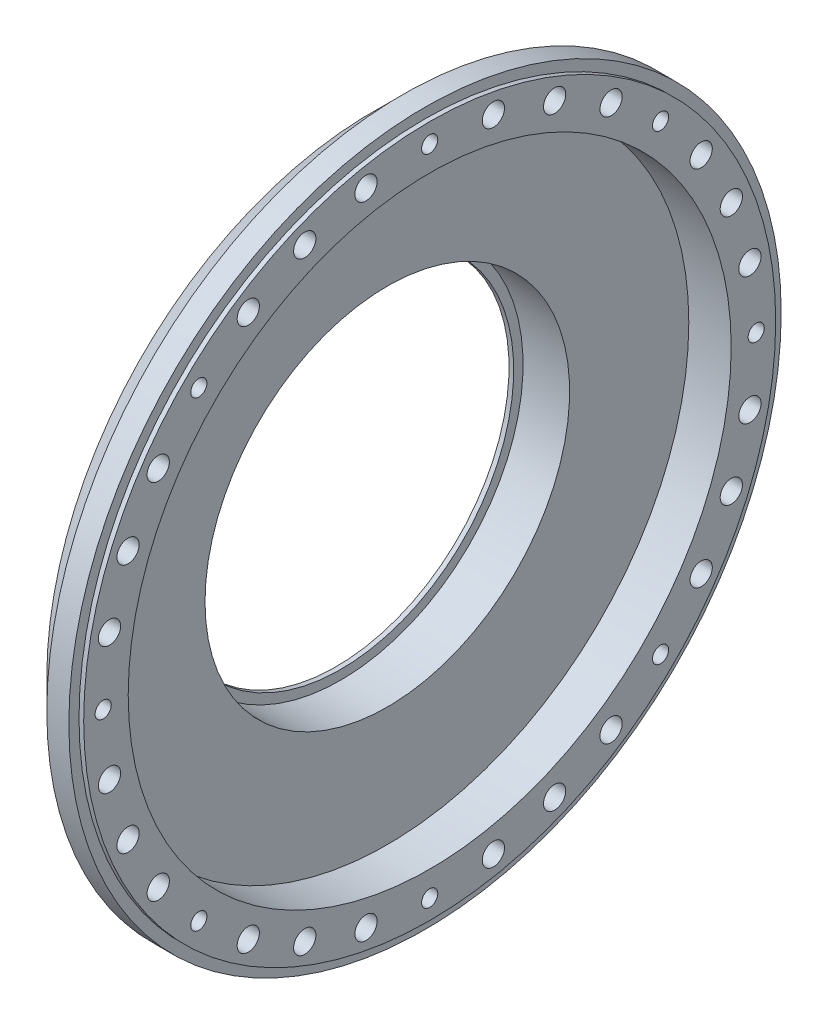
from build123d import *

# Parameters (mm, degrees)
SKETCH5_R          = 2.38125
CUT_EXTRUDE1_DEPTH = 4.445
SKETCH6_R          = 1.7272
CUT_EXTRUDE2_DEPTH = 9.525


with BuildPart() as part:
    # Sketch4 → Revolve1 (revolve)
    with BuildSketch(Plane.XY):
        Polygon((7.249924984, 74.025000032), (6.249924952, 74.025000032), (6.249924952, 76.2), (1.53480008, 76.2), (-4.81519992, 69.85), (-4.81519992, 55.24999999), (-12.775199748, 47.290000162), (-12.775199748, 36.999999914), (-11.775199716, 36.999999914), (-11.775199716, 38.999999978), (-1.815199824, 38.999999978), (-1.815199824, 64.500000032), (7.249924984, 64.500000032), align=None)
    revolve(axis=Axis((0, 0, 0), (1, 0, 0)))

    # Sketch5 → Cut-Extrude1 (cut)
    with BuildSketch(Plane(origin=(7.249924984, 0, 0), x_dir=(0, 0, -1), z_dir=(1, 0, 0))):
        with Locations((13.627058993, 68.507851836)):
            Circle(SKETCH5_R)
        with Locations((26.730437751, 64.532985346)):
            Circle(SKETCH5_R)
        with Locations((38.806580776, 58.078152419)):
            Circle(SKETCH5_R)
        with Locations((58.078152419, 38.806580776)):
            Circle(SKETCH5_R)
        with Locations((64.532985346, 26.730437751)):
            Circle(SKETCH5_R)
        with Locations((68.507851836, 13.627058993)):
            Circle(SKETCH5_R)
        with Locations((68.507851836, -13.627058993)):
            Circle(SKETCH5_R)
        with Locations((64.532985346, -26.730437751)):
            Circle(SKETCH5_R)
        with Locations((58.078152419, -38.806580776)):
            Circle(SKETCH5_R)
        with Locations((38.806580776, -58.078152419)):
            Circle(SKETCH5_R)
        with Locations((26.730437751, -64.532985346)):
            Circle(SKETCH5_R)
        with Locations((13.627058993, -68.507851836)):
            Circle(SKETCH5_R)
        with Locations((-13.627058993, -68.507851836)):
            Circle(SKETCH5_R)
        with Locations((-26.730437751, -64.532985346)):
            Circle(SKETCH5_R)
        with Locations((-38.806580776, -58.078152419)):
            Circle(SKETCH5_R)
        with Locations((-58.078152419, -38.806580776)):
            Circle(SKETCH5_R)
        with Locations((-64.532985346, -26.730437751)):
            Circle(SKETCH5_R)
        with Locations((-68.507851836, -13.627058993)):
            Circle(SKETCH5_R)
        with Locations((-68.507851836, 13.627058993)):
            Circle(SKETCH5_R)
        with Locations((-64.532985346, 26.730437751)):
            Circle(SKETCH5_R)
        with Locations((-58.078152419, 38.806580776)):
            Circle(SKETCH5_R)
        with Locations((-38.806580776, 58.078152419)):
            Circle(SKETCH5_R)
        with Locations((-26.730437751, 64.532985346)):
            Circle(SKETCH5_R)
        with Locations((-13.627058993, 68.507851836)):
            Circle(SKETCH5_R)
    extrude(amount=-CUT_EXTRUDE1_DEPTH, mode=Mode.SUBTRACT)

    # Sketch6 → Cut-Extrude2 (cut)
    with BuildSketch(Plane(origin=(7.249924984, 0, 0), x_dir=(0, 0, -1), z_dir=(1, 0, 0))):
        with Locations((0, 69.85)):
            Circle(SKETCH6_R)
        with Locations((-49.391408666, 49.391408666)):
            Circle(SKETCH6_R)
        with Locations((-69.85, 0)):
            Circle(SKETCH6_R)
        with Locations((-49.391408666, -49.391408666)):
            Circle(SKETCH6_R)
        with Locations((0, -69.85)):
            Circle(SKETCH6_R)
        with Locations((49.391408666, -49.391408666)):
            Circle(SKETCH6_R)
        with Locations((69.85, 0)):
            Circle(SKETCH6_R)
        with Locations((49.391408666, 49.391408666)):
            Circle(SKETCH6_R)
    extrude(amount=-CUT_EXTRUDE2_DEPTH, mode=Mode.SUBTRACT)


solid = part.part
